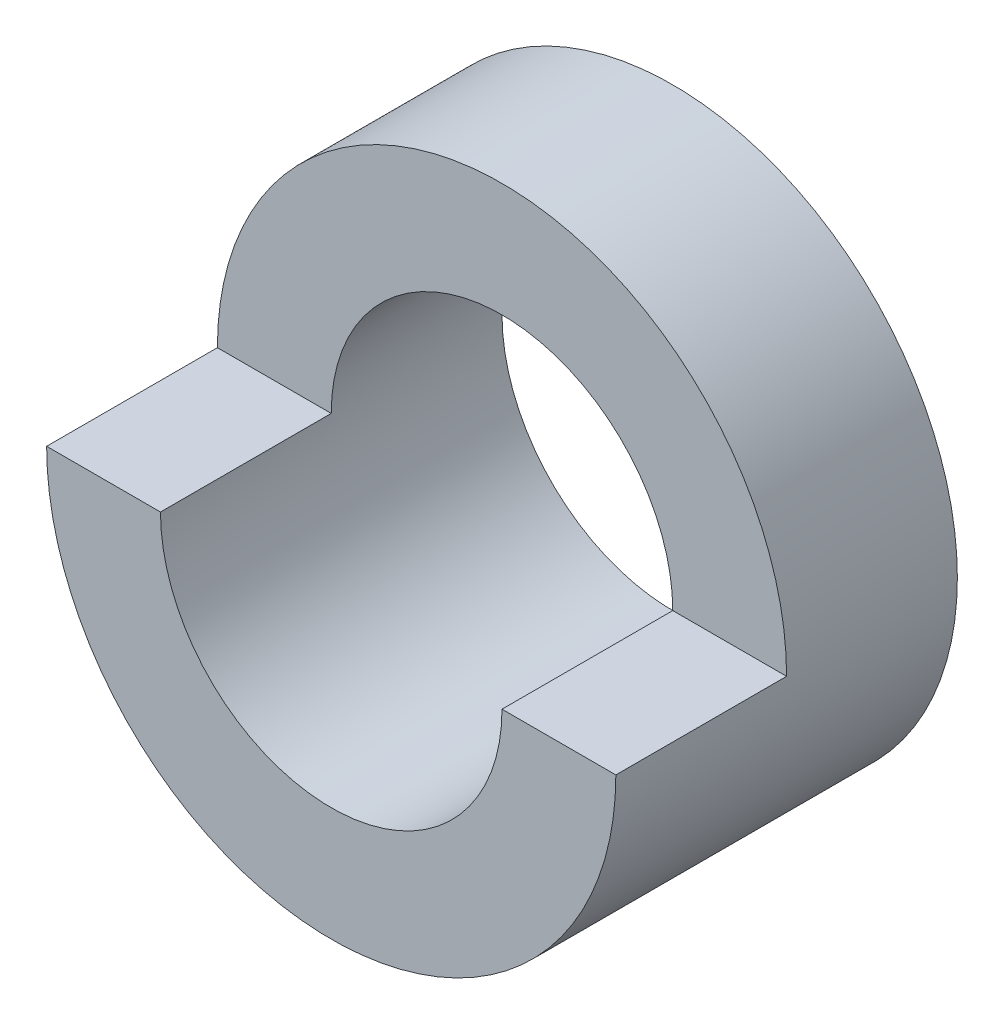
from build123d import *

# Parameters (mm, degrees)
SKETCH1_R           = 50
BOSS_EXTRUDE1_DEPTH = 60
SKETCH2_R           = 30
CUT_EXTRUDE1_DEPTH  = 60
CUT_EXTRUDE2_DEPTH  = 30


with BuildPart() as part:
    # Sketch1 → Boss-Extrude1 (new body)
    with BuildSketch(Plane.XY):
        Circle(SKETCH1_R)
    extrude(amount=BOSS_EXTRUDE1_DEPTH)

    # Sketch2 → Cut-Extrude1 (cut)
    with BuildSketch(Plane.XY.offset(60)):
        Circle(SKETCH2_R)
    extrude(amount=-CUT_EXTRUDE1_DEPTH, mode=Mode.SUBTRACT)

    # Sketch3 → Cut-Extrude2 (cut)
    with BuildSketch(Plane.XY.offset(60)):
        with BuildLine():
            Line((-50, 0), (-30, 0))
            ThreePointArc((-30, 0), (0, 30), (30, 0))
            Line((30, 0), (50, 0))
            ThreePointArc((50, 0), (0, 50), (-50, 0))
        make_face()
    extrude(amount=-CUT_EXTRUDE2_DEPTH, mode=Mode.SUBTRACT)


solid = part.part
